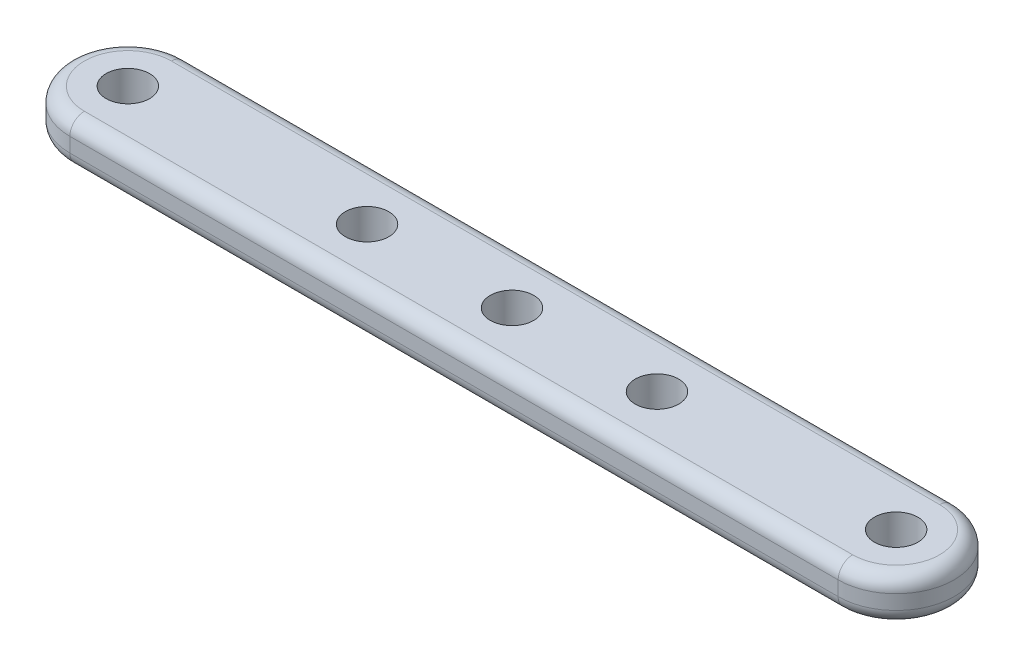
from build123d import *

# Parameters (mm, degrees)
SKETCH1_R           = 1.5
BOSS_EXTRUDE1_DEPTH = 3
FILLET1_R           = 1


with BuildPart() as part:
    # Sketch1 → Boss-Extrude1 (new body)
    with BuildSketch(Plane(origin=(0, 0, 0), x_dir=(1, 0, 0), z_dir=(0, 1, 0))):
        with BuildLine():
            Line((-26.5, 4), (26.5, 4))
            ThreePointArc((26.5, 4), (30.5, 0), (26.5, -4))
            Line((26.5, -4), (-26.5, -4))
            ThreePointArc((-26.5, -4), (-30.5, 0), (-26.5, 4))
        make_face()
        with Locations((-26.5, 0)):
            Circle(SKETCH1_R, mode=Mode.SUBTRACT)
        with Locations((26.5, 0)):
            Circle(SKETCH1_R, mode=Mode.SUBTRACT)
        with Locations((-10, 0)):
            Circle(SKETCH1_R, mode=Mode.SUBTRACT)
        with Locations((10, 0)):
            Circle(SKETCH1_R, mode=Mode.SUBTRACT)
        Circle(SKETCH1_R, mode=Mode.SUBTRACT)
    extrude(amount=BOSS_EXTRUDE1_DEPTH)

    # Fillet1
    fillet1_edges = [part.edges().sort_by_distance(p)[0] for p in [
        (30.5, 0, 0),
        (0, 0, 4),
        (-30.5, 0, 0),
        (0, 0, -4),
        (0, 3, -4),
        (-30.5, 3, 0),
        (0, 3, 4),
        (30.5, 3, 0),
    ]]
    fillet(fillet1_edges, radius=FILLET1_R)


solid = part.part
